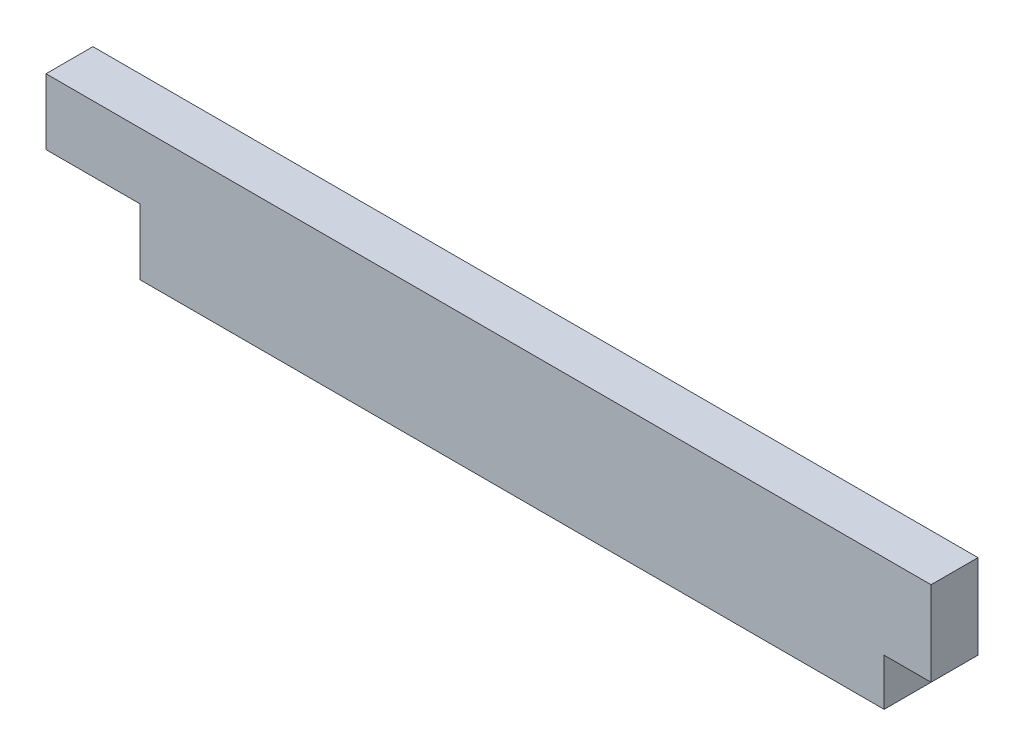
from build123d import *

# Parameters (mm, degrees)
EXTRUDE_1_DEPTH = 1.4


with BuildPart() as part:
    # Эскиз1 → Бобышка-Вытянуть1 (new, symmetric)
    with BuildSketch(Plane.XY):
        Polygon((-26.4, 0), (-20.8, 0), (-20.8, -3.92), (23.6, -3.92), (23.6, -1.12), (26.4, -1.12), (26.4, 3.92), (-26.4, 3.92), align=None)
    extrude(amount=EXTRUDE_1_DEPTH, both=True)


solid = part.part
